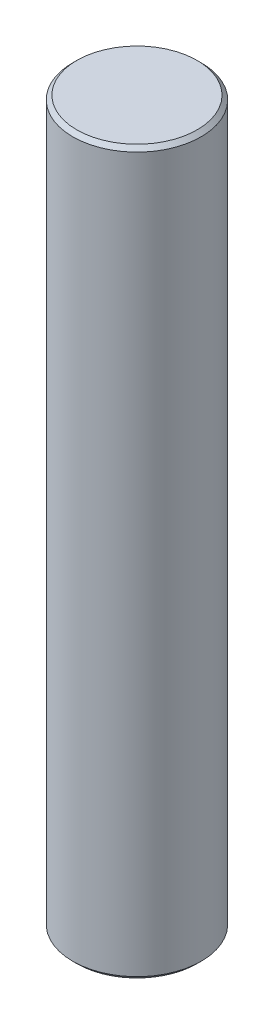
from build123d import *

# Parameters (mm, degrees)
SKETCH1_R           = 16
BOSS_EXTRUDE1_DEPTH = 180
CHAMFER1_SIZE       = 1


with BuildPart() as part:
    # Sketch1 → Boss-Extrude1 (new body)
    with BuildSketch(Plane(origin=(0, 0, 0), x_dir=(1, 0, 0), z_dir=(0, 1, 0))):
        Circle(SKETCH1_R)
    extrude(amount=BOSS_EXTRUDE1_DEPTH)

    # Chamfer1
    chamfer1_edges = [part.edges().sort_by_distance(p)[0] for p in [
        (-16, 0, 0),
        (-16, 180, 0),
    ]]
    chamfer(chamfer1_edges, length=CHAMFER1_SIZE)


solid = part.part
